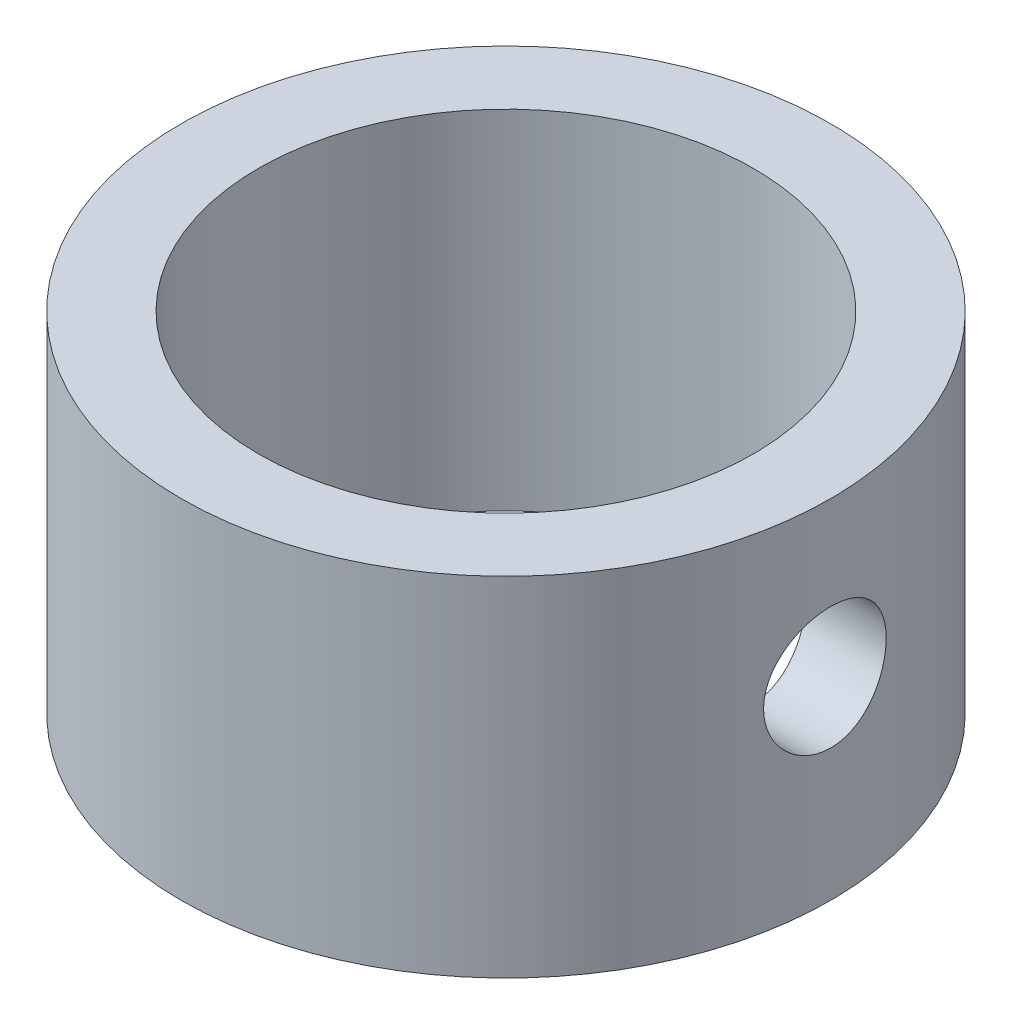
from build123d import *

# Parameters (mm, degrees)
SKETCH1_R                         = 2.1
SKETCH1_R_2                       = 1.6
BOSS_EXTRUDE1_DEPTH               = 1
BOSS_EXTRUDE1_DEPTH_BACK          = 1.25
TAP_DRILL_FOR_100_UNM_TAP9_REACH  = 6.859
TAP_DRILL_FOR_100_UNM_TAP9_BORE_R = 0.39624


with BuildPart() as part:
    # Sketch1 → Boss-Extrude1 (new, two sides)
    with BuildSketch(Plane(origin=(0, 0, 0), x_dir=(1, 0, 0), z_dir=(0, 1, 0))) as boss_extrude1_sk:
        with Locations(Location((0, 0, 0), (0, 0, 270))):
            Circle(SKETCH1_R)
        with Locations(Location((0, 0, 0), (0, 0, 270))):
            Circle(SKETCH1_R_2, mode=Mode.SUBTRACT)
    extrude(amount=BOSS_EXTRUDE1_DEPTH)
    extrude(boss_extrude1_sk.sketch, amount=-BOSS_EXTRUDE1_DEPTH_BACK)

    # Tap Drill for 100 UNM Tap9 bore (on position points) → Tap Drill for 100 UNM Tap9 (cut, up to next)
    with BuildSketch(Plane(origin=(2.1, 0, 0), x_dir=(0, 0, 1), z_dir=(1, 0, 0)), mode=Mode.PRIVATE) as tap_drill_for_100_unm_tap9_sk1:
        Circle(TAP_DRILL_FOR_100_UNM_TAP9_BORE_R)
    tap_drill_for_100_unm_tap9_tool1 = extrude(tap_drill_for_100_unm_tap9_sk1.sketch, amount=-TAP_DRILL_FOR_100_UNM_TAP9_REACH, mode=Mode.PRIVATE) & part.part
    add(tap_drill_for_100_unm_tap9_tool1.solids().sort_by_distance((2.1, 0, 0))[0], mode=Mode.SUBTRACT)


solid = part.part
